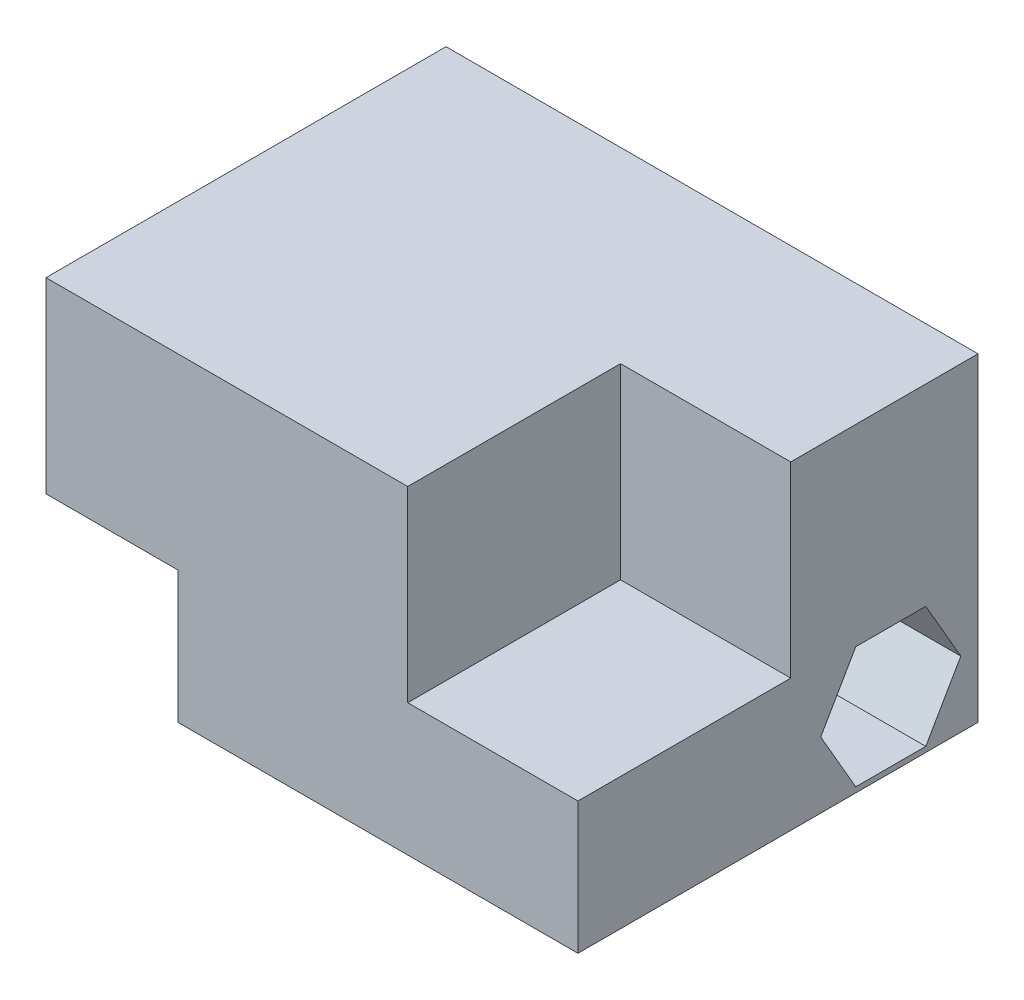
from build123d import *

# Parameters (mm, degrees)
SALIENTE_EXTRUIR1_DEPTH = 8.8
SALIENTE_EXTRUIR2_DEPTH = 10
CORTAR_EXTRUIR1_REACH   = 27
CROQUIS3_R              = 1.6
CORTAR_EXTRUIR2_DEPTH   = 11.8


with BuildPart() as part:
    # Croquis1 → Saliente-Extruir1 (new body)
    with BuildSketch(Plane.XY):
        Polygon((0, 0), (0, 15), (-25, 15), (-25, 6.2), (-18.8, 6.2), (-18.8, 0), align=None)
    extrude(amount=SALIENTE_EXTRUIR1_DEPTH)

    # Croquis2 → Saliente-Extruir2 (add)
    with BuildSketch(Plane.XY.offset(8.8)):
        Polygon((-8, 15), (-8, 6.2), (0, 6.2), (0, 0), (-8, 0), (-18.8, 0), (-18.8, 6.2), (-25, 6.2), (-25, 15), align=None)
    extrude(amount=SALIENTE_EXTRUIR2_DEPTH)

    # Croquis3 → Cortar-Extruir1 (cut, up to next)
    with BuildSketch(Plane(origin=(0, 0, 0), x_dir=(0, 0, -1), z_dir=(1, 0, 0)), mode=Mode.PRIVATE) as cortar_extruir1_sk1:
        with Locations((-4.1, 3.1)):
            Circle(CROQUIS3_R)
    cortar_extruir1_tool1 = extrude(cortar_extruir1_sk1.sketch, amount=-CORTAR_EXTRUIR1_REACH, mode=Mode.PRIVATE) & part.part
    add(cortar_extruir1_tool1.solids().sort_by_distance((0, 3.1, 4.1))[0], mode=Mode.SUBTRACT)

    # Croquis4 → Cortar-Extruir2 (cut)
    with BuildSketch(Plane(origin=(0, 0, 0), x_dir=(0, 0, -1), z_dir=(1, 0, 0))):
        Polygon((-0.809103466, 3.1), (-2.454551733, 5.95), (-5.745448267, 5.95), (-7.390896534, 3.1), (-5.745448267, 0.25), (-2.454551733, 0.25), align=None)
    extrude(amount=-CORTAR_EXTRUIR2_DEPTH, mode=Mode.SUBTRACT)


solid = part.part
